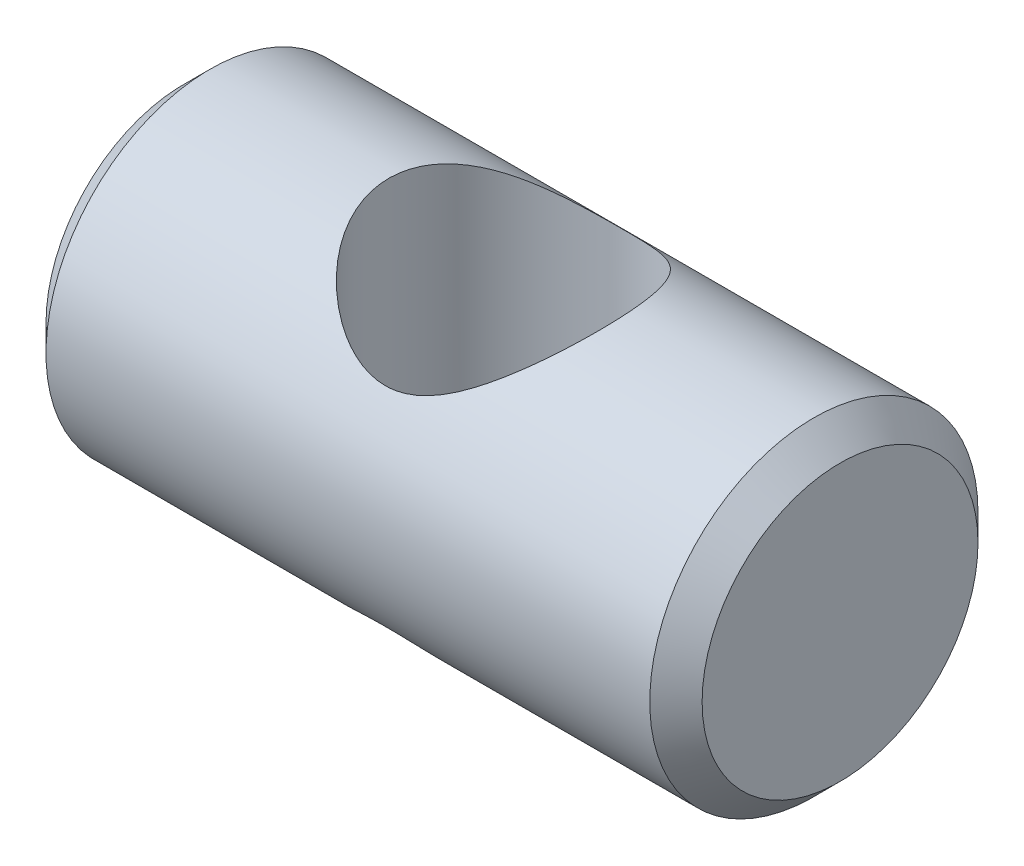
from build123d import *

# Parameters (mm, degrees)
SKETCH1_R           = 4.765
BOSS_EXTRUDE1_DEPTH = 9.525
CHAMFER1_SIZE       = 0.76
SKETCH2_R           = 3.43
CUT_EXTRUDE1_DEPTH  = 9.525


with BuildPart() as part:
    # Sketch1 → Boss-Extrude1 (new body, symmetric)
    with BuildSketch(Plane(origin=(0, 0, 0), x_dir=(0, 0, -1), z_dir=(1, 0, 0))):
        Circle(SKETCH1_R)
    extrude(amount=BOSS_EXTRUDE1_DEPTH, both=True)

    # Chamfer1
    chamfer1_edges = [part.edges().sort_by_distance(p)[0] for p in [
        (-9.525, 0, 4.765),
        (9.525, 0, 4.765),
    ]]
    chamfer(chamfer1_edges, length=CHAMFER1_SIZE)

    # Sketch2 → Cut-Extrude1 (cut, symmetric)
    with BuildSketch(Plane(origin=(0, 0, 0), x_dir=(1, 0, 0), z_dir=(0, 1, 0))):
        with Locations((0, -0.25)):
            Circle(SKETCH2_R)
    extrude(amount=CUT_EXTRUDE1_DEPTH, both=True, mode=Mode.SUBTRACT)


solid = part.part
